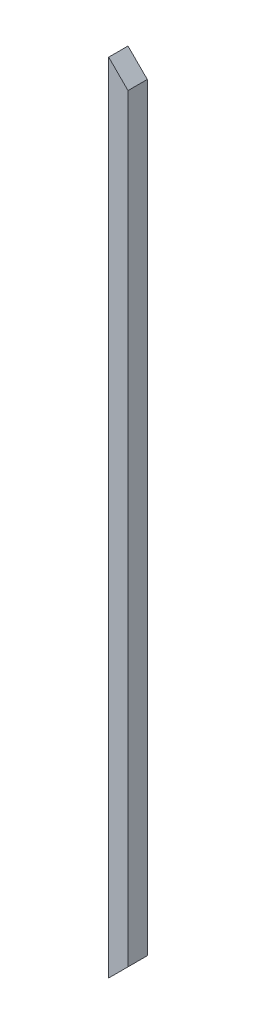
from build123d import *

# Parameters (mm, degrees)
SKETCH1_W           = 19.05
SKETCH1_H           = 19.05
BOSS_EXTRUDE1_DEPTH = 787.4
CUT_EXTRUDE1_DEPTH  = 20.05


with BuildPart() as part:
    # Sketch1 → Boss-Extrude1 (new body)
    with BuildSketch(Plane(origin=(0, 0, 0), x_dir=(1, 0, 0), z_dir=(0, 1, 0))):
        Rectangle(SKETCH1_W, SKETCH1_H)
    extrude(amount=BOSS_EXTRUDE1_DEPTH)

    # Sketch2 → Cut-Extrude1 (cut, through all)
    with BuildSketch(Plane(origin=(0, 0, -9.525), x_dir=(-1, 0, 0), z_dir=(0, 0, -1))):
        Polygon((9.525, 787.4), (-9.525, 768.35), (-9.525, 787.4), align=None)
        Polygon((-9.525, 19.05), (-9.525, 0), (9.525, 0), align=None)
    extrude(amount=-CUT_EXTRUDE1_DEPTH, mode=Mode.SUBTRACT)


solid = part.part
